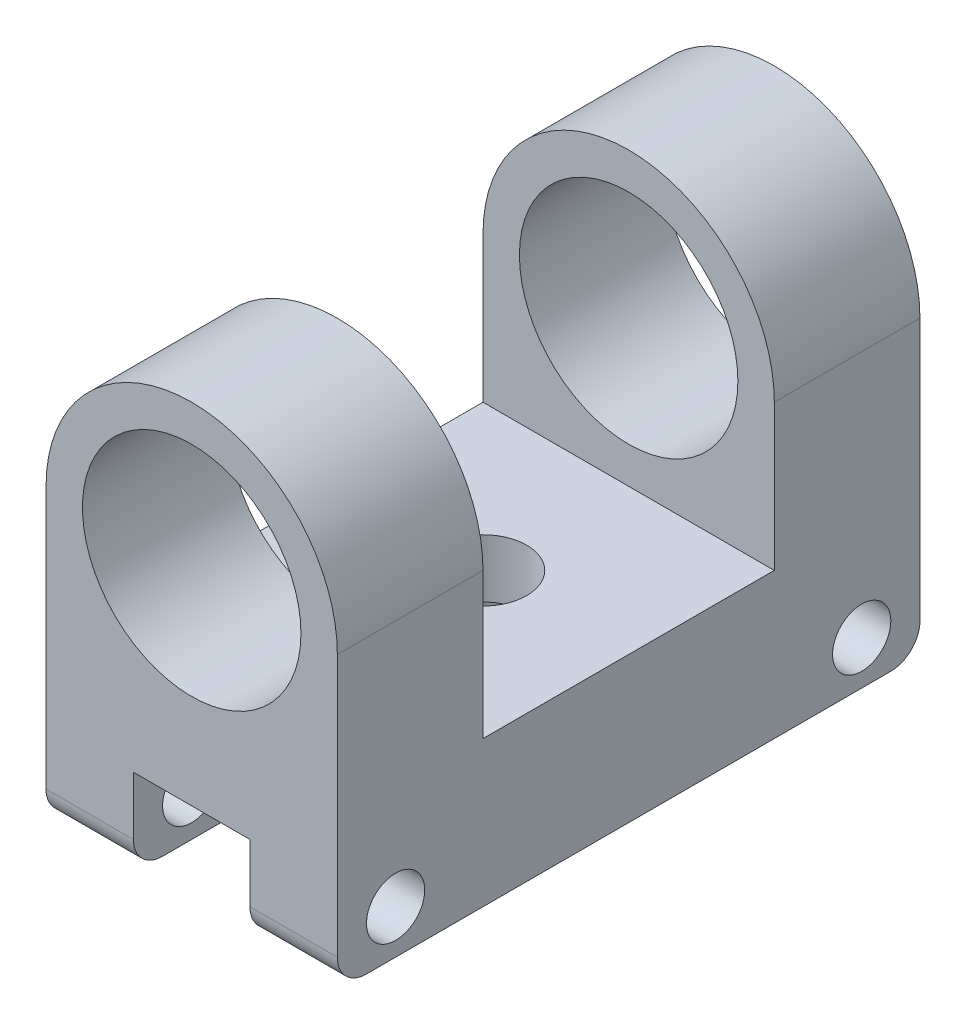
from build123d import *

# Parameters (mm, degrees)
BOSS_EXTRUDE1_DEPTH = 200
SKETCH2_R           = 37.5
SKETCH2_W           = 40
SKETCH2_H           = 30
CUT_EXTRUDE1_DEPTH  = 200
SKETCH3_R           = 10
SKETCH3_W           = 100
SKETCH3_H           = 100
CUT_EXTRUDE2_DEPTH  = 200
SKETCH4_R           = 15
CUT_EXTRUDE3_DEPTH  = 200
FILLET1_R           = 10


with BuildPart() as part:
    # Sketch1 → Boss-Extrude1 (new body)
    with BuildSketch(Plane.XY):
        with BuildLine():
            Line((0, 0), (100, 0))
            Line((100, 0), (100, 100))
            ThreePointArc((100, 100), (50, 150), (0, 100))
            Line((0, 100), (0, 0))
        make_face()
    extrude(amount=-BOSS_EXTRUDE1_DEPTH)

    # Sketch2 → Cut-Extrude1 (cut)
    with BuildSketch(Plane.XY):
        with Locations((50, 100)):
            Circle(SKETCH2_R)
        with Locations((50, 15)):
            Rectangle(SKETCH2_W, SKETCH2_H)
    extrude(amount=-CUT_EXTRUDE1_DEPTH, mode=Mode.SUBTRACT)

    # Sketch3 → Cut-Extrude2 (cut)
    with BuildSketch(Plane(origin=(100, 0, 0), x_dir=(0, 0, -1), z_dir=(1, 0, 0))):
        with Locations((20, 15)):
            Circle(SKETCH3_R)
        with Locations((180, 15)):
            Circle(SKETCH3_R)
        with Locations((100, 100)):
            Rectangle(SKETCH3_W, SKETCH3_H)
    extrude(amount=-CUT_EXTRUDE2_DEPTH, mode=Mode.SUBTRACT)

    # Sketch4 → Cut-Extrude3 (cut)
    with BuildSketch(Plane(origin=(0, 50, 0), x_dir=(1, 0, 0), z_dir=(0, 1, 0))):
        with Locations((50, 100)):
            Circle(SKETCH4_R)
    extrude(amount=-CUT_EXTRUDE3_DEPTH, mode=Mode.SUBTRACT)

    # Fillet1
    fillet1_edges = [part.edges().sort_by_distance(p)[0] for p in [
        (85, 0, 0),
        (85, 0, -200),
        (15, 0, 0),
        (15, 0, -200),
    ]]
    fillet(fillet1_edges, radius=FILLET1_R)


solid = part.part
